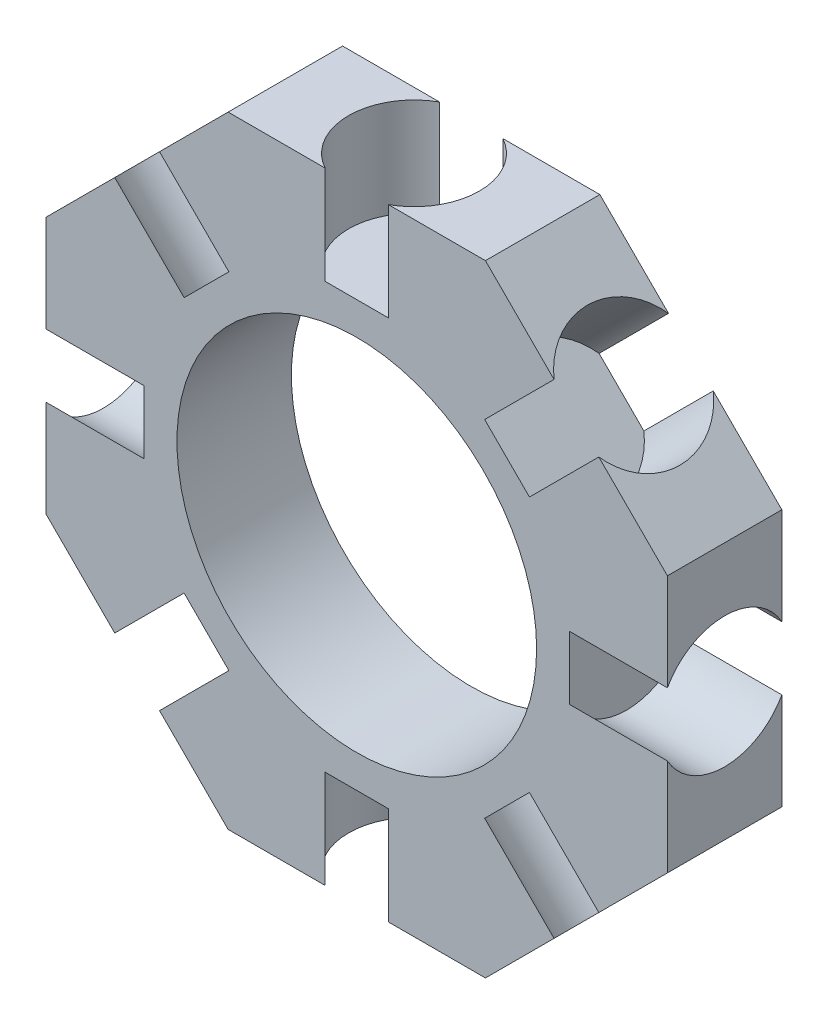
from build123d import *

# Parameters (mm, degrees)
SKETCH1_R           = 11
BOSS_EXTRUDE1_DEPTH = 3.5
SKETCH2_R           = 4
CUT_EXTRUDE3_DEPTH  = 6
CIRPATTERN1_COUNT   = 8


with BuildPart() as part:
    # Sketch1 → Boss-Extrude1 (new, symmetric)
    with BuildSketch(Plane.XY):
        Polygon((7.870057685, 19), (-7.870057685, 19), (-19, 7.870057685), (-19, -7.870057685), (-7.870057685, -19), (7.870057685, -19), (19, -7.870057685), (19, 7.870057685), align=None)
        Circle(SKETCH1_R, mode=Mode.SUBTRACT)
    extrude(amount=BOSS_EXTRUDE1_DEPTH, both=True)

    # Sketch2 → Cut-Extrude3 (cut)
    with BuildSketch(Plane(origin=(0, -19, 0), x_dir=(-1, 0, 0), z_dir=(0, -1, 0))):
        Circle(SKETCH2_R)
    cut_extrude3 = extrude(amount=-CUT_EXTRUDE3_DEPTH, mode=Mode.SUBTRACT)

    # CirPattern1: Cut-Extrude3 ×8 about axis
    cirpattern1_axis = Axis((0, 0, 3.5), (0, 0, 1))
    for i in range(1, CIRPATTERN1_COUNT):
        add(cut_extrude3.rotate(cirpattern1_axis, i * 360 / CIRPATTERN1_COUNT), mode=Mode.SUBTRACT)


solid = part.part
